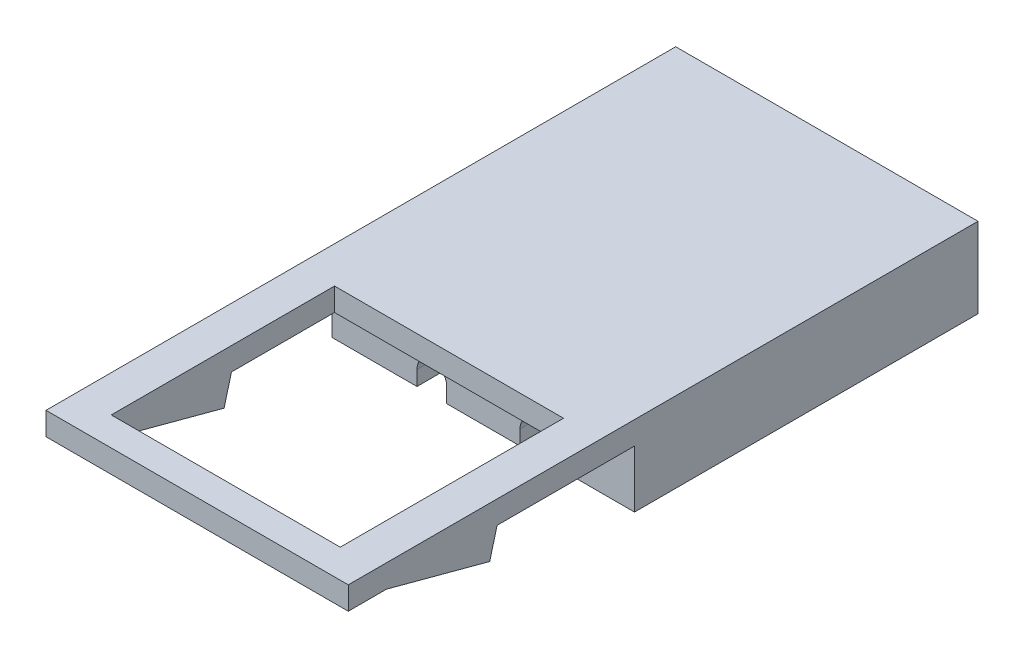
from build123d import *

# Parameters (mm, degrees)
SKETCH1_W           = 63.5
SKETCH1_H           = 35
BOSS_EXTRUDE1_DEPTH = 12
SKETCH3_W           = 26.4
SKETCH3_H           = 35
CUT_EXTRUDE2_DEPTH  = 5
SKETCH4_W           = 2.6
SKETCH4_H           = 35
CUT_EXTRUDE3_DEPTH  = 1.3
SKETCH5_W           = 18.55
SKETCH5_H           = 35
CUT_EXTRUDE4_DEPTH  = 13
SKETCH6_W           = 18.55
SKETCH6_H           = 35
CUT_EXTRUDE5_DEPTH  = 13
SKETCH7_R           = 2.5
CUT_EXTRUDE6_DEPTH  = 36
SKETCH8_R           = 2.5
CUT_EXTRUDE7_DEPTH  = 36
SKETCH12_W          = 26.4
SKETCH12_H          = 10
BOSS_EXTRUDE2_DEPTH = 27
SKETCH13_W          = 20
SKETCH13_H          = 19.5
CUT_EXTRUDE8_DEPTH  = 11
SKETCH14_W          = 27
SKETCH14_H          = 3
CUT_EXTRUDE9_DEPTH  = 27.4
SKETCH18_W          = 2.6
SKETCH18_H          = 1.3
CUT_EXTRUDE12_DEPTH = 28
SKETCH19_W          = 10
SKETCH19_H          = 5
CUT_EXTRUDE13_DEPTH = 27.4
SKETCH20_W          = 2.5
SKETCH20_H          = 5
CUT_EXTRUDE14_DEPTH = 27.4
CUT_EXTRUDE15_DEPTH = 27.4
SKETCH24_W          = 26.4
SKETCH24_H          = 2
CUT_EXTRUDE18_DEPTH = 5
SKETCH25_W          = 26.4
SKETCH25_H          = 7
CUT_EXTRUDE19_DEPTH = 8
SKETCH26_R          = 1.3
CUT_EXTRUDE20_DEPTH = 56


with BuildPart() as part:
    # Sketch1 → Boss-Extrude1 (new body)
    with BuildSketch(Plane(origin=(0, 0, 0), x_dir=(1, 0, 0), z_dir=(0, 1, 0))):
        with Locations((0, 17.5)):
            Rectangle(SKETCH1_W, SKETCH1_H)
    extrude(amount=BOSS_EXTRUDE1_DEPTH)

    # Sketch3 → Cut-Extrude2 (cut)
    with BuildSketch(Plane.XZ):
        with Locations((0, -17.5)):
            Rectangle(SKETCH3_W, SKETCH3_H)
    extrude(amount=-CUT_EXTRUDE2_DEPTH, mode=Mode.SUBTRACT)

    # Sketch4 → Cut-Extrude3 (cut)
    with BuildSketch(Plane.XZ.offset(-5)):
        with Locations((-4.5, -17.5)):
            Rectangle(SKETCH4_W, SKETCH4_H)
        with Locations((4.5, -17.5)):
            Rectangle(SKETCH4_W, SKETCH4_H)
    extrude(amount=-CUT_EXTRUDE3_DEPTH, mode=Mode.SUBTRACT)

    # Sketch5 → Cut-Extrude4 (cut, through all)
    with BuildSketch(Plane.XZ):
        with Locations((-22.475, -17.5)):
            Rectangle(SKETCH5_W, SKETCH5_H)
    extrude(amount=-CUT_EXTRUDE4_DEPTH, mode=Mode.SUBTRACT)

    # Sketch6 → Cut-Extrude5 (cut, through all)
    with BuildSketch(Plane.XZ):
        with Locations((22.475, -17.5)):
            Rectangle(SKETCH6_W, SKETCH6_H)
    extrude(amount=-CUT_EXTRUDE5_DEPTH, mode=Mode.SUBTRACT)

    # Sketch7 → Cut-Extrude6 (cut, through all)
    with BuildSketch(Plane.XY):
        with Locations((-9, 8.5)):
            Circle(SKETCH7_R)
    extrude(amount=-CUT_EXTRUDE6_DEPTH, mode=Mode.SUBTRACT)

    # Sketch8 → Cut-Extrude7 (cut, through all)
    with BuildSketch(Plane.XY):
        with Locations((9, 8.5)):
            Circle(SKETCH8_R)
    extrude(amount=-CUT_EXTRUDE7_DEPTH, mode=Mode.SUBTRACT)

    # Sketch12 → Boss-Extrude2 (add)
    with BuildSketch(Plane.XY):
        with Locations((0, 10)):
            Rectangle(SKETCH12_W, SKETCH12_H)
    extrude(amount=BOSS_EXTRUDE2_DEPTH)

    # Sketch13 → Cut-Extrude8 (cut, through all)
    with BuildSketch(Plane(origin=(0, 15, 0), x_dir=(1, 0, 0), z_dir=(0, 1, 0))):
        with Locations((0, -14.75)):
            Rectangle(SKETCH13_W, SKETCH13_H)
    extrude(amount=-CUT_EXTRUDE8_DEPTH, mode=Mode.SUBTRACT)

    # Sketch14 → Cut-Extrude9 (cut, through all)
    with BuildSketch(Plane.ZY.offset(13.2)):
        with Locations((13.5, 13.5)):
            Rectangle(SKETCH14_W, SKETCH14_H)
    extrude(amount=-CUT_EXTRUDE9_DEPTH, mode=Mode.SUBTRACT)

    # Sketch18 → Cut-Extrude12 (cut, through all)
    with BuildSketch(Plane(origin=(0, 0, 0), x_dir=(-1, 0, 0), z_dir=(0, 0, -1))):
        with Locations((4.5, 5.65)):
            Rectangle(SKETCH18_W, SKETCH18_H)
        with Locations((-4.5, 5.65)):
            Rectangle(SKETCH18_W, SKETCH18_H)
    extrude(amount=-CUT_EXTRUDE12_DEPTH, mode=Mode.SUBTRACT)

    # Sketch19 → Cut-Extrude13 (cut, through all)
    with BuildSketch(Plane.ZY.offset(13.2)):
        with Locations((9, 7.5)):
            Rectangle(SKETCH19_W, SKETCH19_H)
    extrude(amount=-CUT_EXTRUDE13_DEPTH, mode=Mode.SUBTRACT)

    # Sketch20 → Cut-Extrude14 (cut, through all)
    with BuildSketch(Plane.ZY.offset(13.2)):
        with Locations((25.75, 7.5)):
            Rectangle(SKETCH20_W, SKETCH20_H)
    extrude(amount=-CUT_EXTRUDE14_DEPTH, mode=Mode.SUBTRACT)

    # Sketch21 → Cut-Extrude15 (cut, through all)
    with BuildSketch(Plane.ZY.offset(13.2)):
        Polygon((14, 10), (14.647047613, 7.585185434), (23.6593, 10), (24.5, 10), (24.5, 5), (14, 5), align=None)
    extrude(amount=-CUT_EXTRUDE15_DEPTH, mode=Mode.SUBTRACT)

    # Sketch24 → Cut-Extrude18 (cut)
    with BuildSketch(Plane.XZ.offset(-5)):
        with Locations((0, 3)):
            Rectangle(SKETCH24_W, SKETCH24_H)
    extrude(amount=-CUT_EXTRUDE18_DEPTH, mode=Mode.SUBTRACT)

    # Sketch25 → Cut-Extrude19 (cut, through all)
    with BuildSketch(Plane(origin=(0, 12, 0), x_dir=(1, 0, 0), z_dir=(0, 1, 0))):
        with Locations((0, 31.5)):
            Rectangle(SKETCH25_W, SKETCH25_H)
    extrude(amount=-CUT_EXTRUDE19_DEPTH, mode=Mode.SUBTRACT)

    # Sketch26 → Cut-Extrude20 (cut, through all)
    with BuildSketch(Plane(origin=(0, 0, -28), x_dir=(-1, 0, 0), z_dir=(0, 0, -1))):
        with Locations((4.5, 6.3)):
            Circle(SKETCH26_R)
        with Locations((-4.5, 6.3)):
            Circle(SKETCH26_R)
    extrude(amount=-CUT_EXTRUDE20_DEPTH, mode=Mode.SUBTRACT)


solid = part.part
